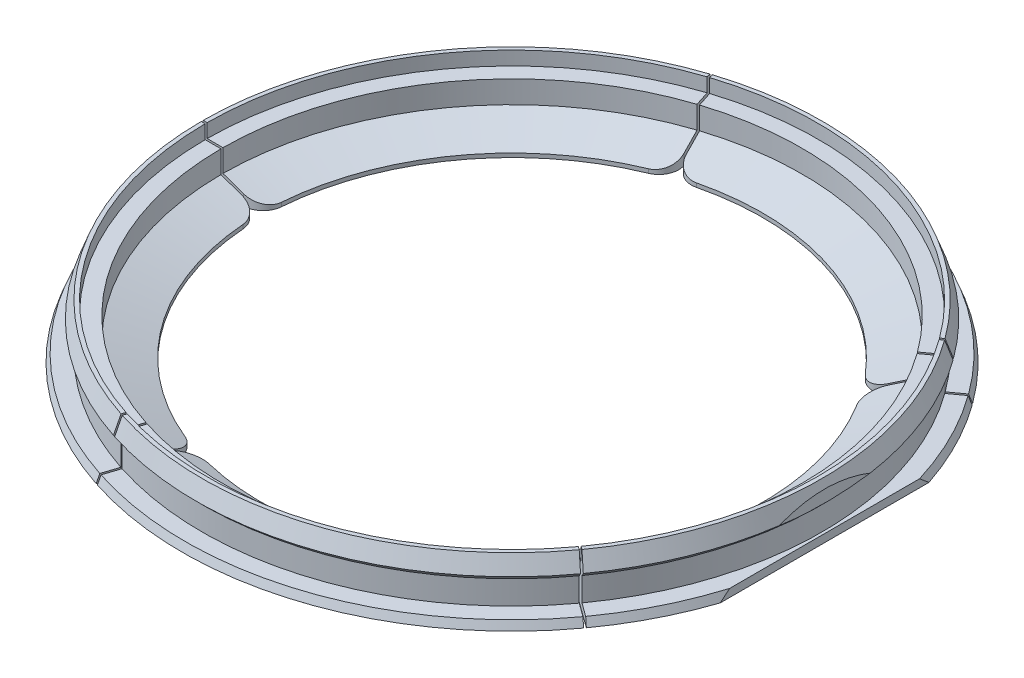
from build123d import *

# Parameters (mm, degrees)
CUT_EXTRUDE1_DEPTH      = 14.7
SKETCH4_W               = 52.41384378
SKETCH4_H               = 0.5
CUT_EXTRUDE3_DEPTH      = 14.7
CUT_EXTRUDE3_DEPTH_BACK = 1
FILLET2_R               = 5
FILLET3_R               = 5
FILLET4_R               = 5
FILLET5_R               = 5
FILLET6_R               = 5


with BuildPart() as part:
    # Sketch1 → Revolve1 (revolve)
    with BuildSketch(Plane.XY):
        Polygon((63.5, 0), (63.5, 1), (73.5, 4.53484861), (73.5, 10.2), (77.5, 10.2), (77.5, 13.7), (78.5, 13.7), (80.032846715, 9.5), (78.532846715, 8), (78.532846715, 2), (82.770072993, 2), (83.5, 0), align=None)
    revolve(axis=Axis((0, 0, 0), (0, 1, 0)))

    # Sketch2 → Cut-Extrude1 (cut, through all)
    with BuildSketch(Plane(origin=(0, 0, 0), x_dir=(1, 0, 0), z_dir=(0, 1, 0))):
        with BuildLine():
            Line((79.2, 26.450141777), (79.2, -26.450141777))
            ThreePointArc((79.2, -26.450141777), (83.5, 0), (79.2, 26.450141777))
        make_face()
    extrude(amount=CUT_EXTRUDE1_DEPTH, mode=Mode.SUBTRACT)

    # Sketch4 → Cut-Extrude3 (cut, two sides)
    with BuildSketch(Plane(origin=(0, 0, 0), x_dir=(1, 0, 0), z_dir=(0, 1, 0))) as cut_extrude3_sk:
        Polygon((-31.102458296, 96.532540857), (-31.577986554, 96.378032359), (-15.381218085, 46.529504688), (-14.905689827, 46.684013185), align=None)
        with Locations((-75.212168306, 0)):
            Rectangle(SKETCH4_W, SKETCH4_H)
        Polygon((82.196713836, 59.41039127), (81.90282121, 59.814899767), (39.499130851, 29.006815377), (39.793023477, 28.60230688), align=None)
        Polygon((81.90282121, -59.814899767), (82.196713836, -59.41039127), (39.793023477, -28.60230688), (39.499130851, -29.006815377), align=None)
        Polygon((-31.577986554, -96.378032359), (-31.102458296, -96.532540857), (-14.905689827, -46.684013185), (-15.381218085, -46.529504688), align=None)
    extrude(amount=CUT_EXTRUDE3_DEPTH, mode=Mode.SUBTRACT)
    extrude(cut_extrude3_sk.sketch, amount=-CUT_EXTRUDE3_DEPTH_BACK, mode=Mode.SUBTRACT)

    # Fillet2
    fillet2_edges = [part.edges().sort_by_distance(p)[0] for p in [
        (-19.860191196, 0.5, -60.314366495),
        (-63.499507872, 0.5, -0.25),
    ]]
    fillet(fillet2_edges, radius=FILLET2_R)

    # Fillet3
    fillet3_edges = [part.edges().sort_by_distance(p)[0] for p in [
        (-19.860191196, 0.5, 60.314366495),
        (-63.499507872, 0.5, 0.25),
    ]]
    fillet(fillet3_edges, radius=FILLET3_R)

    # Fillet4
    fillet4_edges = [part.edges().sort_by_distance(p)[0] for p in [
        (51.22523469, 0.5, 37.526328504),
        (-19.384662938, 0.5, 60.468874992),
    ]]
    fillet(fillet4_edges, radius=FILLET4_R)

    # Fillet5
    fillet5_edges = [part.edges().sort_by_distance(p)[0] for p in [
        (51.519127316, 0.5, -37.121820006),
        (51.519127316, 0.5, 37.121820006),
    ]]
    fillet(fillet5_edges, radius=FILLET5_R)

    # Fillet6
    fillet6_edges = [part.edges().sort_by_distance(p)[0] for p in [
        (51.22523469, 0.5, -37.526328504),
        (-19.384662938, 0.5, -60.468874992),
    ]]
    fillet(fillet6_edges, radius=FILLET6_R)


solid = part.part
